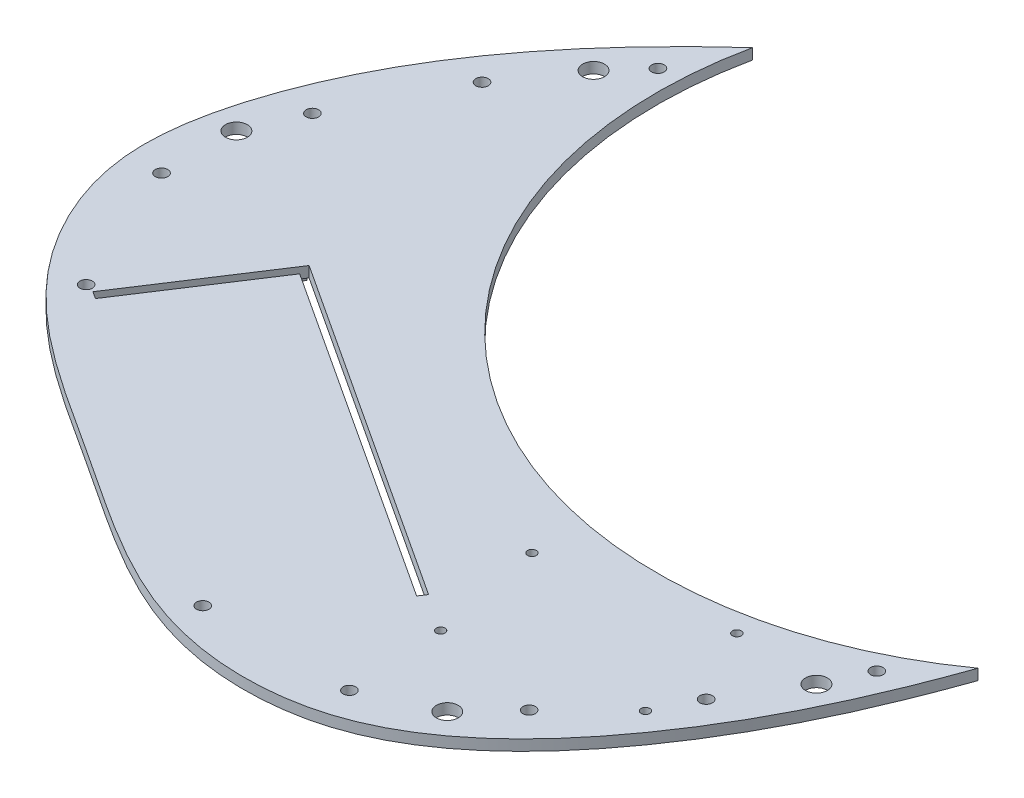
from build123d import *

# Parameters (mm, degrees)
SKETCH1_R           = 4.97264949
BOSS_EXTRUDE1_DEPTH = 2.5
BOSS_EXTRUDE2_DEPTH = 2.5
SKETCH5_R           = 1.016
CUT_EXTRUDE1_DEPTH  = 2.5
SKETCH7_R           = 1.45
CUT_EXTRUDE2_DEPTH  = 22.5
BOSS_EXTRUDE3_DEPTH = 2.032
BOSS_EXTRUDE4_DEPTH = 1.27
FILLET1_R           = 1.27
BOSS_EXTRUDE5_DEPTH = 6.35
BOSS_EXTRUDE6_DEPTH = 2.54
FILLET2_R           = 1.27
SKETCH12_R          = 2.54
CUT_EXTRUDE3_DEPTH  = 2.54
CUT_EXTRUDE5_DEPTH  = 2
CUT_EXTRUDE6_DEPTH  = 30.194


with BuildPart() as part:
    # Sketch1 → Boss-Extrude1 (new body)
    with BuildSketch(Plane(origin=(0, 0, 0), x_dir=(1, 0, 0), z_dir=(0, 1, 0))):
        with Locations((0, 29.077302231)):
            Circle(SKETCH1_R)
    extrude(amount=BOSS_EXTRUDE1_DEPTH)

    # Sketch4 → Boss-Extrude2 (add)
    with BuildSketch(Plane(origin=(0, 2.5, 0), x_dir=(1, 0, 0), z_dir=(0, 1, 0))):
        with BuildLine():
            ThreePointArc((127.836218959, 60.021860615), (18.663418588, 57.644090539), (-23.014266624, 158.576368263))
            add(Edge.make_bspline(
                [(-23.014266624, 158.576368263), (-43.525367802, 139.93455507), (-67.441977329, 110.606484637), (-77.052944274, 62.289470054), (-62.282256217, 29.91559378), (-37.705476382, 11.981691021), (-7.341817226, -7.185244534), (21.54144366, -27.925689472), (71.869897241, -27.621486723), (107.505543827, 10.898265089), (121.770537032, 42.910179385), (127.836218959, 60.021860615)],
                knots=[0, 0, 0, 0, 0.208614632, 0.280863848, 0.361665291, 0.463000863, 0.507838165, 0.636520929, 0.725181857, 0.864472991, 1, 1, 1, 1], degree=3))
        make_face()
    extrude(amount=-BOSS_EXTRUDE2_DEPTH)

    # Sketch5 → Cut-Extrude1 (cut)
    with BuildSketch(Plane(origin=(0, 0, 0), x_dir=(-1, 0, 0), z_dir=(0, -1, 0))):
        with Locations((-97.851116061, 12.855849852)):
            Circle(SKETCH5_R)
        with Locations((-57.931274745, 5.239034946)):
            Circle(SKETCH5_R)
        with Locations((-52.932739964, 31.43643081)):
            Circle(SKETCH5_R)
        with Locations((-92.85258128, 39.053245715)):
            Circle(SKETCH5_R)
    extrude(amount=-CUT_EXTRUDE1_DEPTH, mode=Mode.SUBTRACT)

    # Sketch7 → Cut-Extrude2 (cut)
    with BuildSketch(Plane(origin=(0, 0, 0), x_dir=(-1, 0, 0), z_dir=(0, -1, 0))):
        with Locations((-116.68461242, 47.699513218)):
            Circle(SKETCH7_R)
        with Locations((-102.537696022, 22.242682357)):
            Circle(SKETCH7_R)
        with Locations((-84.180454065, -0.470688376)):
            Circle(SKETCH7_R)
        with Locations((-59.363446928, -17.358898913)):
            Circle(SKETCH7_R)
        with Locations((-25.335433541, -17.358898913)):
            Circle(SKETCH7_R)
        with Locations((-67.32001575, 301.077348787)):
            Circle(SKETCH7_R)
        with Locations((-100.185198085, 292.257740796)):
            Circle(SKETCH7_R)
        with Locations((-119.776940348, 269.514409168)):
            Circle(SKETCH7_R)
        with Locations((-131.619861457, 242.819264255)):
            Circle(SKETCH7_R)
        with Locations((-138.685267106, 214.565671137)):
            Circle(SKETCH7_R)
    cut_extrude2 = extrude(amount=-CUT_EXTRUDE2_DEPTH, mode=Mode.SUBTRACT)

    # Sketch8 → Boss-Extrude3 (add)
    with BuildSketch(Plane.XZ):
        Polygon((23.117644184, -31.083224589), (21.52283704, -32.125153173), (30.732959389, -46.222442701), (32.327766533, -45.180514117), align=None)
        Polygon((3.355436755, -64.108883393), (-5.854685594, -50.011593865), (-7.449492738, -51.05352245), (1.760629611, -65.150811977), align=None)
        Polygon((-33.704030791, -65.930762463), (-34.745959375, -64.335955319), (-48.765005719, -73.49495938), (-47.723077135, -75.089766524), align=None)
        Polygon((-62.753901245, -43.571070108), (-52.632400064, -36.95843269), (-53.674328648, -35.363625546), (-63.795829829, -41.976262964), align=None)
    extrude(amount=BOSS_EXTRUDE3_DEPTH)

    # Sketch9 → Boss-Extrude4 (add)
    with BuildSketch(Plane(origin=(0, -2.032, 0), x_dir=(-1, 0, 0), z_dir=(0, -1, 0))):
        Polygon((-32.327766533, 45.180514117), (-23.117644184, 31.083224589), (-19.928029897, 33.167081757), (-29.138152245, 47.264371285), align=None)
        Polygon((-1.760629611, 65.150811977), (7.449492738, 51.05352245), (4.25987845, 48.969665281), (-4.950243898, 63.066954809), align=None)
        Polygon((47.723077135, 75.089766524), (33.704030791, 65.930762463), (35.787887959, 62.741148175), (49.806934303, 71.900152237), align=None)
        Polygon((63.795829829, 41.976262964), (53.674328648, 35.363625546), (51.59047148, 38.553239833), (61.711972661, 45.165877251), align=None)
    extrude(amount=BOSS_EXTRUDE4_DEPTH)

    # Fillet1
    fillet1_edges = [part.edges().sort_by_distance(p)[0] for p in [
        (-57.693150655, -2.032, -40.264751399),
        (-41.755482547, -2.032, -68.91545735),
        (-1.24962442, -2.032, -57.060238629),
        (26.127898215, -2.032, -39.173797937),
    ]]
    fillet(fillet1_edges, radius=FILLET1_R)

    # Sketch10 → Boss-Extrude5 (add)
    with BuildSketch(Plane(origin=(0, 0, 0), x_dir=(-1, 0, 0), z_dir=(0, -1, 0))):
        Polygon((-20.78323121, 20.143116325), (-5.223764355, -3.672670355), (-3.09735483, -2.283432243), (-18.656821685, 21.532354437), align=None)
        Polygon((28.124187865, 52.095592902), (43.68365472, 28.279806222), (41.557245195, 26.89056811), (25.99777834, 50.70635479), align=None)
    extrude(amount=BOSS_EXTRUDE5_DEPTH)

    # Sketch11 → Boss-Extrude6 (add)
    with BuildSketch(Plane(origin=(0, -6.35, 0), x_dir=(-1, 0, 0), z_dir=(0, -1, 0))):
        Polygon((-20.78323121, 20.143116325), (-5.223764355, -3.672670355), (0.092259457, -0.199575075), (-15.467207398, 23.616211605), align=None)
        Polygon((28.124187865, 52.095592902), (43.68365472, 28.279806222), (38.367630907, 24.806710942), (22.808164052, 48.622497622), align=None)
    extrude(amount=BOSS_EXTRUDE6_DEPTH)

    # Fillet2
    fillet2_edges = [part.edges().sort_by_distance(p)[0] for p in [
        (-33.777511767, -6.35, -38.79846145),
        (10.877088258, -6.35, -9.624461097),
    ]]
    fillet(fillet2_edges, radius=FILLET2_R)

    # Sketch12 → Cut-Extrude3 (cut)
    with BuildSketch(Plane(origin=(0, 0, 0), x_dir=(-1, 0, 0), z_dir=(0, -1, 0))):
        with Locations((-112.311361387, 38.067382066)):
            Circle(SKETCH12_R)
        with Locations((-74.984918834, -10.268193029)):
            Circle(SKETCH12_R)
        with Locations((66.153161532, 81.94095013)):
            Circle(SKETCH12_R)
        with Locations((36.883107015, 135.539971036)):
            Circle(SKETCH12_R)
    extrude(amount=-CUT_EXTRUDE3_DEPTH, mode=Mode.SUBTRACT)

    # Mirror1: Cut-Extrude2 across plane
    add(cut_extrude2.mirror(Plane(origin=(-13.314052816, 0, -8.698413631), x_dir=(-0.546944139, 0, 0.837169104), z_dir=(0.837169104, 0, 0.546944139))), mode=Mode.SUBTRACT)

    # Sketch14 → Cut-Extrude5 (cut)
    with BuildSketch(Plane.XZ):
        Polygon((23.90086027, -51.033953629), (14.531428558, -36.69282041), (7.834075723, -41.068373519), (17.203507436, -55.409506738), align=None)
        Polygon((17.203507436, -55.409506738), (7.834075723, -41.068373519), (1.136722888, -45.443926628), (10.506154601, -59.785059847), align=None)
        Polygon((-60.34251494, -71.08326122), (-39.313626611, -57.344546839), (-43.68917972, -50.647194004), (-64.718068049, -64.385908386), align=None)
        Polygon((-64.718068049, -64.385908386), (-43.68917972, -50.647194004), (-48.064732829, -43.94984117), (-69.093621158, -57.688555551), align=None)
    extrude(amount=-CUT_EXTRUDE5_DEPTH, mode=Mode.SUBTRACT)

    # Sketch15 → Cut-Extrude6 (cut)
    with BuildSketch(Plane(origin=(0, 0, 0), x_dir=(-1, 0, 0), z_dir=(0, -1, 0))):
        Polygon((29.003478162, 62.237748811), (-49.298194521, 11.081249252), (-48.204306243, 9.406911043), (30.097366439, 60.563410603), align=None)
        Polygon((30.677816371, 63.331637088), (29.003478162, 62.237748811), (30.097366439, 60.563410603), (31.771704648, 61.65729888), align=None)
        Polygon((31.771704648, 61.65729888), (30.097366439, 60.563410603), (48.821051629, 31.904376427), (50.495389838, 32.998264704), align=None)
    extrude(amount=-CUT_EXTRUDE6_DEPTH, mode=Mode.SUBTRACT)


solid = part.part
